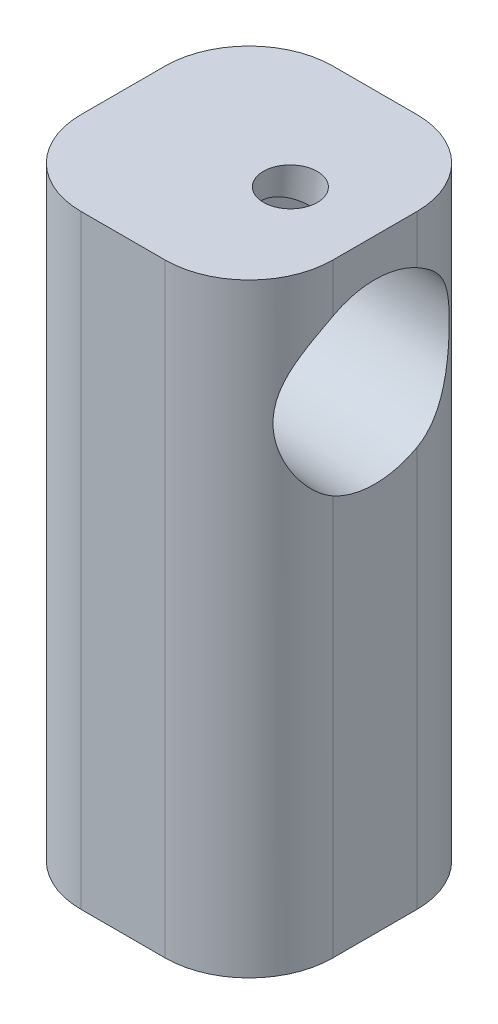
from build123d import *

# Parameters (mm, degrees)
SKETCH1_W                      = 15
SKETCH1_H                      = 15
SKETCH1_R                      = 4.15
BOSS_EXTRUDE1_DEPTH            = 20
SKETCH2_W                      = 15
SKETCH2_H                      = 15
BOSS_EXTRUDE2_DEPTH            = 16
FILLET1_R                      = 5
CUT_EXTRUDE1_DEPTH             = 39.422077783
CUT_EXTRUDE1_DEPTH_BACK        = 39.422077783
SKETCH3_R                      = 2.5
CUT_EXTRUDE2_DEPTH             = 39.422077783
CUT_EXTRUDE2_DEPTH_BACK        = 7
SKETCH4_R                      = 5.25
CUT_EXTRUDE3_REACH             = 44.637
SKETCH5_R                      = 1.6
CUT_EXTRUDE3_DIRECTION_2_DEPTH = 10
CHAMFER1_SIZE                  = 10
CHAMFER1_SIZE2                 = 0.174550649


with BuildPart() as part:
    # Sketch1 → Boss-Extrude1 (new body)
    with BuildSketch(Plane(origin=(0, 0, 0), x_dir=(1, 0, 0), z_dir=(0, 1, 0))):
        Rectangle(SKETCH1_W, SKETCH1_H)
        Circle(SKETCH1_R, mode=Mode.SUBTRACT)
    extrude(amount=BOSS_EXTRUDE1_DEPTH)

    # Sketch2 → Boss-Extrude2 (add)
    with BuildSketch(Plane(origin=(0, 20, 0), x_dir=(1, 0, 0), z_dir=(0, 1, 0))):
        Rectangle(SKETCH2_W, SKETCH2_H)
    extrude(amount=BOSS_EXTRUDE2_DEPTH)

    # Fillet1
    fillet1_edges = [part.edges().sort_by_distance(p)[0] for p in [
        (-7.5, 18, -7.5),
        (7.5, 18, -7.5),
        (-7.5, 18, 7.5),
        (7.5, 18, 7.5),
    ]]
    fillet(fillet1_edges, radius=FILLET1_R)

    # Sketch3 → Cut-Extrude1 (cut, two sides: drawn at the far end of the back side and taken through both)
    with BuildSketch(Plane(origin=(4.046061336, 0.129475488, 0), x_dir=(0, 0, -1), z_dir=(0.9953961983671789, -0.09584575252022422, 0)).offset(-CUT_EXTRUDE1_DEPTH_BACK)):
        with Locations((0, 28.536429083)):
            Circle(SKETCH3_R)
    extrude(amount=CUT_EXTRUDE1_DEPTH + CUT_EXTRUDE1_DEPTH_BACK, mode=Mode.SUBTRACT)

    # Sketch4 → Cut-Extrude2 (cut, two sides: drawn at the far end of the back side and taken through both)
    with BuildSketch(Plane(origin=(4.046061336, 0.129475488, 0), x_dir=(0, 0, -1), z_dir=(0.9953961983671789, -0.09584575252022422, 0)).offset(-CUT_EXTRUDE2_DEPTH_BACK)):
        with Locations((0, 28.536429083)):
            Circle(SKETCH4_R)
    extrude(amount=CUT_EXTRUDE2_DEPTH + CUT_EXTRUDE2_DEPTH_BACK, mode=Mode.SUBTRACT)

    # Sketch5 → Cut-Extrude3 (cut, up to next)
    with BuildSketch(Plane(origin=(15.282832762, 35.250598441, 0), x_dir=(-0.9953961983671784, 0.09584575252022766, 0), z_dir=(-0.09584575252022767, -0.9953961983671784, 0)), mode=Mode.PRIVATE) as cut_extrude3_sk1:
        with Locations((12.833853497, 0)):
            Circle(SKETCH5_R)
    cut_extrude3_tool1 = extrude(cut_extrude3_sk1.sketch, amount=CUT_EXTRUDE3_REACH, mode=Mode.PRIVATE) & part.part
    add(cut_extrude3_tool1.solids().sort_by_distance((2.508064, 36.480669, 0))[0], mode=Mode.SUBTRACT)

    # Sketch5 → Cut-Extrude3 direction 2 (cut)
    with BuildSketch(Plane(origin=(15.282832762, 35.250598441, 0), x_dir=(-0.9953961983671784, 0.09584575252022766, 0), z_dir=(-0.09584575252022767, -0.9953961983671784, 0))):
        with Locations((12.833853497, 0)):
            Circle(SKETCH5_R)
    extrude(amount=-CUT_EXTRUDE3_DIRECTION_2_DEPTH, mode=Mode.SUBTRACT)

    # Chamfer1
    chamfer1_edges = [part.edges().sort_by_distance(p)[0] for p in [
        (-4.15, 20, 0),
    ]]
    chamfer1_side = [part.faces().sort_by_distance(p)[0] for p in [
        (-4.15, 10, 0),
    ]]
    chamfer(chamfer1_edges, length=CHAMFER1_SIZE, length2=CHAMFER1_SIZE2, reference=chamfer1_side[0])


solid = part.part
